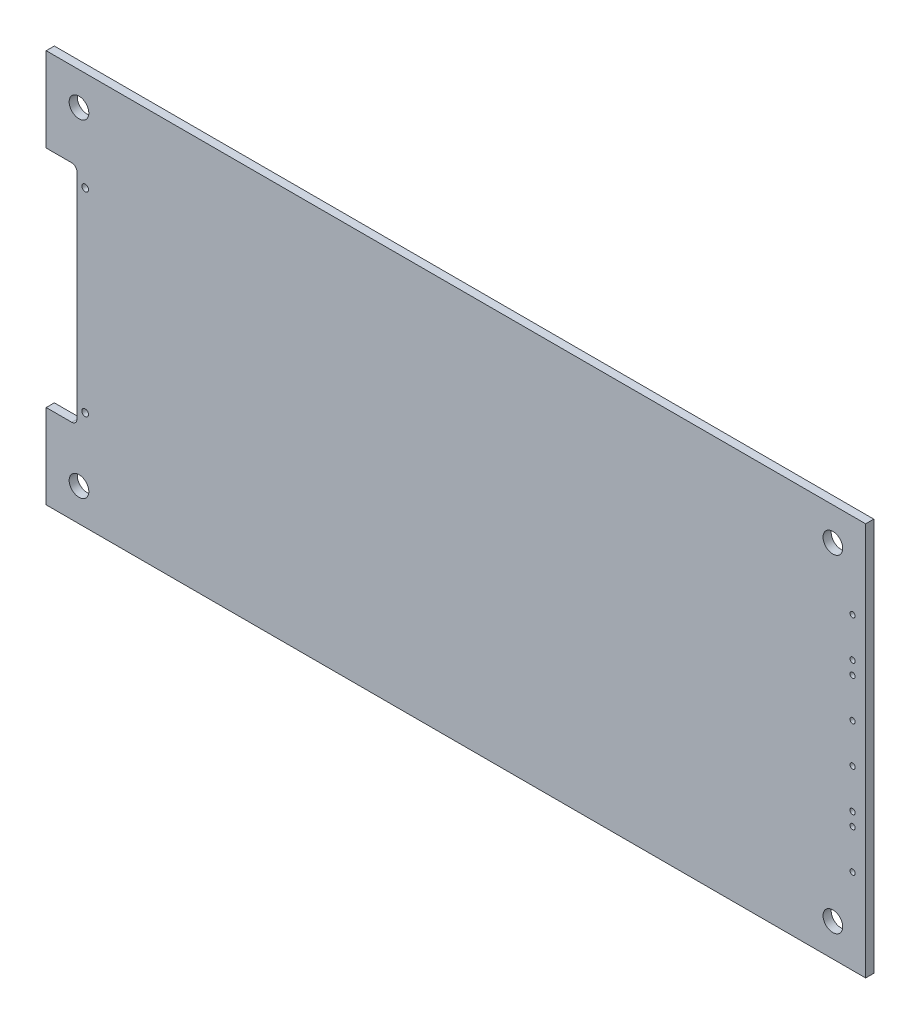
from build123d import *

# Parameters (mm, degrees)
SKETCH1_W               = 158.75
SKETCH1_H               = 76.2
EXTRUDE1_DEPTH          = 1.5748
SKETCH2_R               = 1.905
CUT_EXTRUDE2_DEPTH      = 1.5748
SKETCH4_R               = 0.65
CUT_EXTRUDE3_DEPTH      = 1.5748
SKETCH5_R               = 0.508
TRANSCEIVER_HOLES_DEPTH = 2.54
LPATTERN1_COUNT         = 2
LPATTERN1_PITCH         = 25.4


with BuildPart() as part:
    # Sketch1 → Extrude1 (new body)
    with BuildSketch(Plane.XY):
        with Locations((79.375, -38.1)):
            Rectangle(SKETCH1_W, SKETCH1_H)
    extrude(amount=EXTRUDE1_DEPTH)

    # Sketch2 → Cut-Extrude2 (cut)
    with BuildSketch(Plane.XY.offset(1.5748)):
        with Locations((152.4, -6.35)):
            Circle(SKETCH2_R)
        with Locations((6.35, -6.35)):
            Circle(SKETCH2_R)
        with Locations((152.4, -69.85)):
            Circle(SKETCH2_R)
        with Locations((6.35, -69.85)):
            Circle(SKETCH2_R)
    extrude(amount=-CUT_EXTRUDE2_DEPTH, mode=Mode.SUBTRACT)

    # Sketch4 → Cut-Extrude3 (cut)
    with BuildSketch(Plane.XY.offset(1.5748)):
        with Locations((7.55, -19.234912)):
            Circle(SKETCH4_R)
        with Locations((7.55, -56.965088)):
            Circle(SKETCH4_R)
        with BuildLine():
            Line((0, -16.335006), (4.95, -16.335006))
            ThreePointArc((4.95, -16.335006), (5.657106781, -16.627899219), (5.95, -17.335006))
            Line((5.95, -17.335006), (5.95, -58.865006))
            ThreePointArc((5.95, -58.865006), (5.657106781, -59.572112781), (4.95, -59.865006))
            Line((4.95, -59.865006), (0, -59.865006))
            Line((0, -59.865006), (0, -16.335006))
        make_face()
    extrude(amount=-CUT_EXTRUDE3_DEPTH, mode=Mode.SUBTRACT)

    # Sketch5 → transceiver holes (cut)
    with BuildSketch(Plane.XY.offset(1.5748)):
        with Locations((156.21, -59.69)):
            Circle(SKETCH5_R)
        with Locations((156.21, -52.07)):
            Circle(SKETCH5_R)
        with Locations((156.21, -49.53)):
            Circle(SKETCH5_R)
        with Locations((156.21, -41.91)):
            Circle(SKETCH5_R)
    transceiver_holes = extrude(amount=-TRANSCEIVER_HOLES_DEPTH, mode=Mode.SUBTRACT)

    # LPattern1: transceiver holes ×2
    with Locations(*[(0, i * LPATTERN1_PITCH, 0) for i in range(1, LPATTERN1_COUNT)]):
        add(transceiver_holes, mode=Mode.SUBTRACT)


solid = part.part
